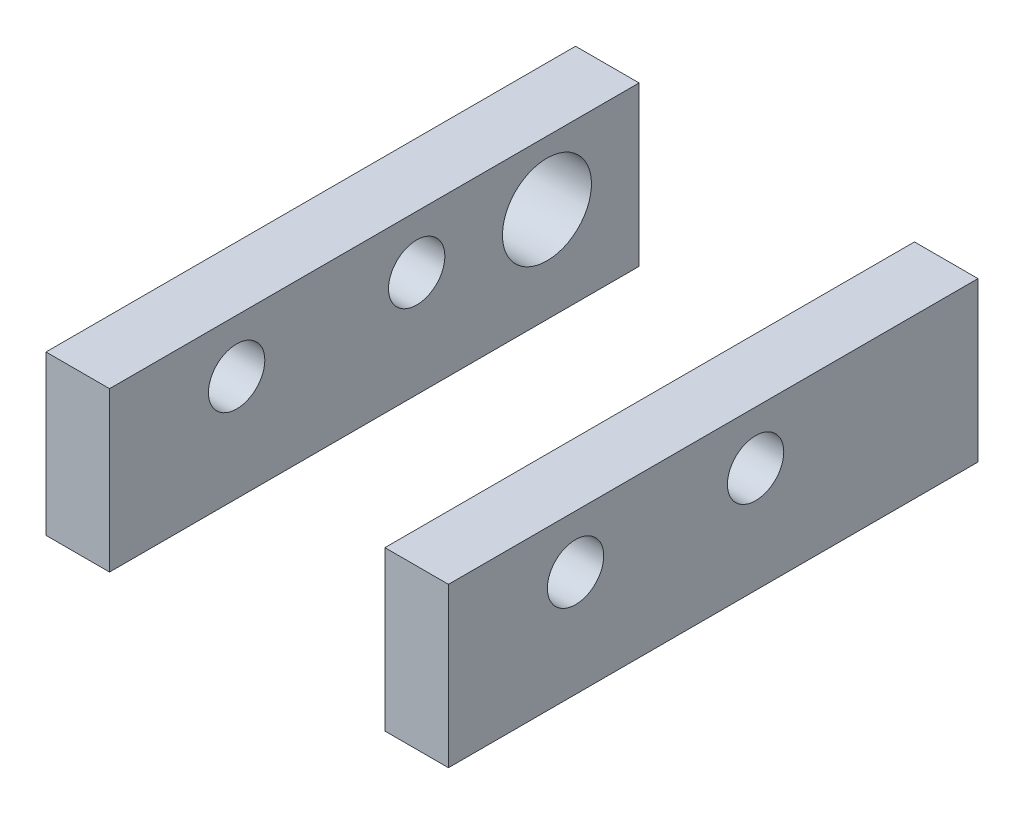
from build123d import *

# Parameters (mm, degrees)
BOSS_EXTRUDE1_DEPTH            = 63.5
CUT_EXTRUDE1_REACH             = 50.26
SKETCH2_R                      = 5.334
SKETCH3_R                      = 3.3782
CUT_EXTRUDE2_DEPTH             = 49.26
CUT_EXTRUDE4_REACH             = 65.5
SKETCH5_W                      = 33.02
SKETCH5_H                      = 2.54
CUT_EXTRUDE4_DIRECTION_2_DEPTH = 1
SKETCH6_R                      = 3.3782
CUT_EXTRUDE5_DEPTH             = 49.26


with BuildPart() as part:
    # Sketch1 → Boss-Extrude1 (new body)
    with BuildSketch(Plane.XY):
        Polygon((-7.62, 16.51), (0, 16.51), (0, 0), (33.02, 0), (33.02, 16.51), (40.64, 16.51), (40.64, -2.54), (-7.62, -2.54), align=None)
    extrude(amount=BOSS_EXTRUDE1_DEPTH)

    # Sketch2 → Cut-Extrude1 (cut, up to next)
    with BuildSketch(Plane.ZY.offset(7.62), mode=Mode.PRIVATE) as cut_extrude1_sk1:
        with Locations((11.049, 8.89)):
            Circle(SKETCH2_R)
    cut_extrude1_tool1 = extrude(cut_extrude1_sk1.sketch, amount=-CUT_EXTRUDE1_REACH, mode=Mode.PRIVATE) & part.part
    add(cut_extrude1_tool1.solids().sort_by_distance((-7.62, 8.89, 11.049))[0], mode=Mode.SUBTRACT)

    # Sketch3 → Cut-Extrude2 (cut, through all)
    with BuildSketch(Plane(origin=(40.64, 0, 0), x_dir=(0, 0, -1), z_dir=(1, 0, 0))):
        with Locations((-48.26, 10.16)):
            Circle(SKETCH3_R)
    extrude(amount=-CUT_EXTRUDE2_DEPTH, mode=Mode.SUBTRACT)

    # Sketch5 → Cut-Extrude4 (cut, up to next)
    with BuildSketch(Plane.XY.offset(63.5), mode=Mode.PRIVATE) as cut_extrude4_sk1:
        with Locations((16.51, -1.27)):
            Rectangle(SKETCH5_W, SKETCH5_H)
    cut_extrude4_tool1 = extrude(cut_extrude4_sk1.sketch, amount=-CUT_EXTRUDE4_REACH, mode=Mode.PRIVATE) & part.part
    add(cut_extrude4_tool1.solids().sort_by_distance((16.51, -1.27, 63.5))[0], mode=Mode.SUBTRACT)

    # Sketch5 → Cut-Extrude4 direction 2 (cut)
    with BuildSketch(Plane.XY.offset(63.5)):
        with Locations((16.51, -1.27)):
            Rectangle(SKETCH5_W, SKETCH5_H)
    extrude(amount=CUT_EXTRUDE4_DIRECTION_2_DEPTH, mode=Mode.SUBTRACT)

    # Sketch6 → Cut-Extrude5 (cut, through all)
    with BuildSketch(Plane(origin=(40.64, 0, 0), x_dir=(0, 0, -1), z_dir=(1, 0, 0))):
        with Locations((-26.67, 10.16)):
            Circle(SKETCH6_R)
    extrude(amount=-CUT_EXTRUDE5_DEPTH, mode=Mode.SUBTRACT)


solid = part.part
